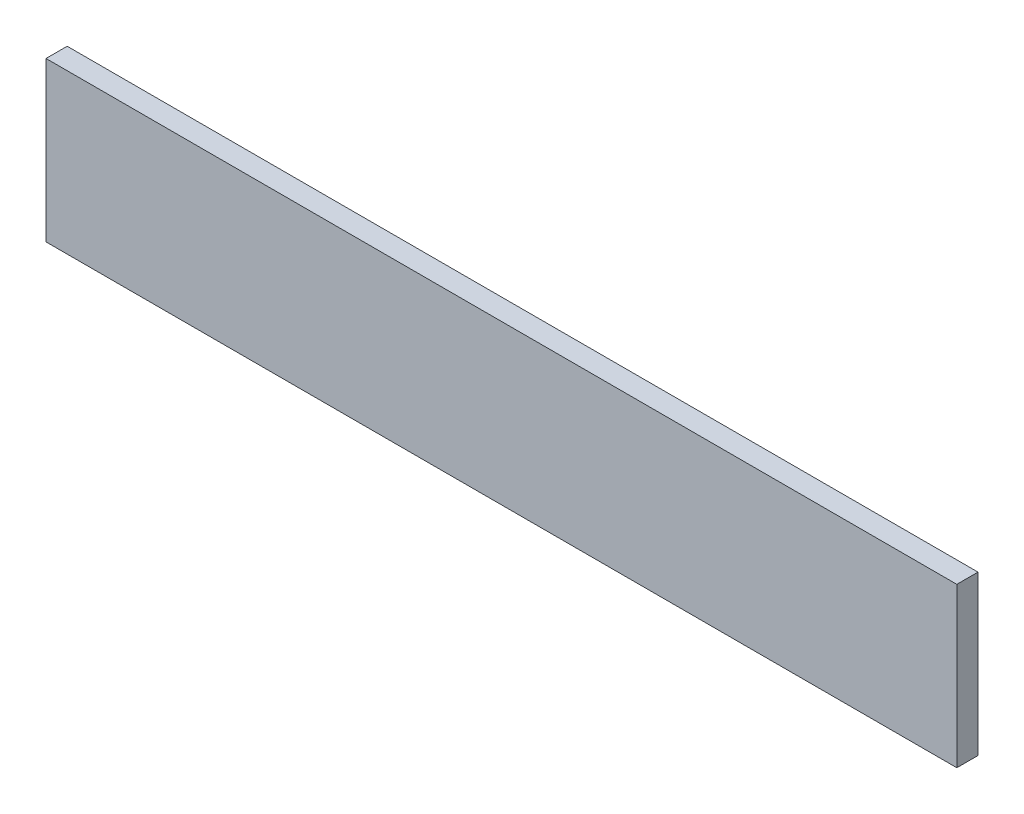
from build123d import *

# Parameters (mm, degrees)
CROQUIS1_W              = 860
CROQUIS1_H              = 150
SALIENTE_EXTRUIR1_DEPTH = 20


with BuildPart() as part:
    # Croquis1 → Saliente-Extruir1 (new body)
    with BuildSketch(Plane.XY):
        with Locations((-183.953092608, 161.823308271)):
            Rectangle(CROQUIS1_W, CROQUIS1_H)
    extrude(amount=SALIENTE_EXTRUIR1_DEPTH)


solid = part.part
